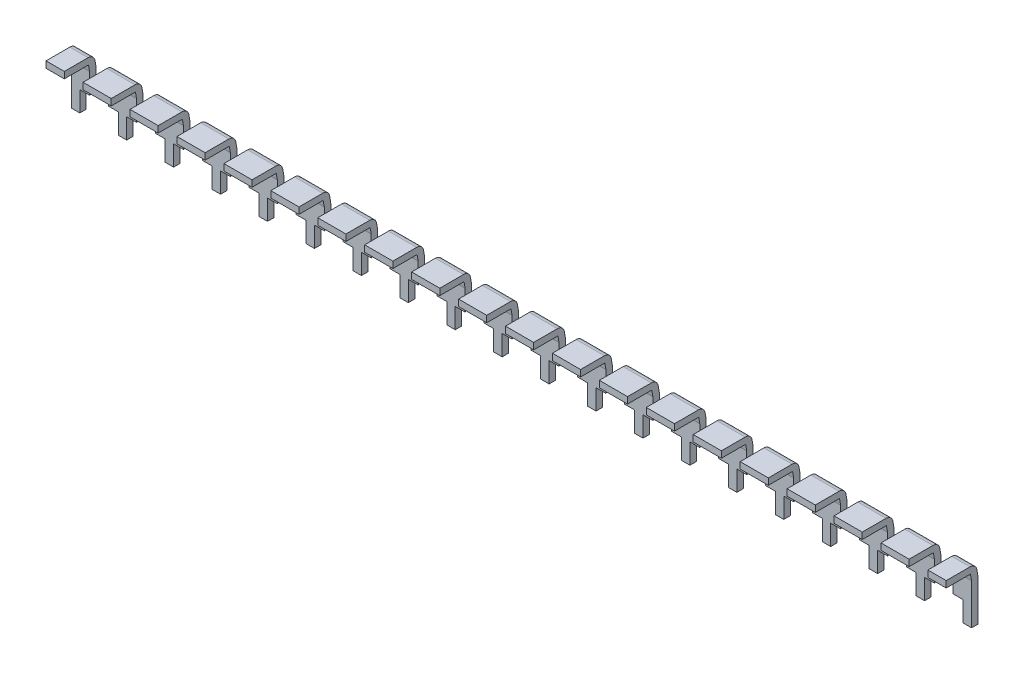
from build123d import *

# Parameters (mm, degrees)
SKETCH1_W      = 1.524
SKETCH1_H      = 0.35
SKETCH1_W_2    = 0.9906
SKETCH10_W     = 0.5334
SKETCH10_H     = 1.139083415
EXTRUDE1_DEPTH = 3.082895174


with BuildPart() as part:
    # Sweep11: sweep along a path in Sketch2
    with BuildLine(Plane(origin=(0, 0, 0), x_dir=(0, 0, -1), z_dir=(1, 0, 0))) as sweep11_path:
        Line((0, 0), (1.289016583, 0))
        ThreePointArc((1.289016583, 0), (1.417574105, -0.046791111), (1.485978134, -0.165270364))
        Line((1.485978134, -0.165270364), (1.541961551, -0.482768097))
        ThreePointArc((1.541961551, -0.482768097), (1.54423894, -0.500066584), (1.545, -0.517497733))
        Line((1.545, -0.517497733), (1.545, -2.725))
    # Sketch1 → Sweep11 (sweep)
    with BuildSketch(Plane.XY):
        with Locations((-1.27, 0)):
            Rectangle(SKETCH1_W, SKETCH1_H)
        with Locations((21.59, 0)):
            Rectangle(SKETCH1_W, SKETCH1_H)
        with Locations((23.8633, 0)):
            Rectangle(SKETCH1_W_2, SKETCH1_H)
        with Locations((-23.8633, 0)):
            Rectangle(SKETCH1_W_2, SKETCH1_H)
        with Locations((1.27, 0)):
            Rectangle(SKETCH1_W, SKETCH1_H)
        with Locations((3.81, 0)):
            Rectangle(SKETCH1_W, SKETCH1_H)
        with Locations((6.35, 0)):
            Rectangle(SKETCH1_W, SKETCH1_H)
        with Locations((8.89, 0)):
            Rectangle(SKETCH1_W, SKETCH1_H)
        with Locations((11.43, 0)):
            Rectangle(SKETCH1_W, SKETCH1_H)
        with Locations((13.97, 0)):
            Rectangle(SKETCH1_W, SKETCH1_H)
        with Locations((16.51, 0)):
            Rectangle(SKETCH1_W, SKETCH1_H)
        with Locations((19.05, 0)):
            Rectangle(SKETCH1_W, SKETCH1_H)
        with Locations((-3.81, 0)):
            Rectangle(SKETCH1_W, SKETCH1_H)
        with Locations((-6.35, 0)):
            Rectangle(SKETCH1_W, SKETCH1_H)
        with Locations((-8.89, 0)):
            Rectangle(SKETCH1_W, SKETCH1_H)
        with Locations((-11.43, 0)):
            Rectangle(SKETCH1_W, SKETCH1_H)
        with Locations((-13.97, 0)):
            Rectangle(SKETCH1_W, SKETCH1_H)
        with Locations((-16.51, 0)):
            Rectangle(SKETCH1_W, SKETCH1_H)
        with Locations((-19.05, 0)):
            Rectangle(SKETCH1_W, SKETCH1_H)
        with Locations((-21.59, 0)):
            Rectangle(SKETCH1_W, SKETCH1_H)
    sweep(path=sweep11_path.line)

    # Sketch10 → Extrude1 (cut, through all)
    with BuildSketch(Plane(origin=(0, 0.279522147, -1.585248871), x_dir=(-1, 0, 0), z_dir=(0, 0.173648178, -0.984807753))):
        with Locations((-23.6347, -2.412734286)):
            Rectangle(SKETCH10_W, SKETCH10_H)
        with Locations((-22.0853, -2.412734286)):
            Rectangle(SKETCH10_W, SKETCH10_H)
        with Locations((-21.0947, -2.412734286)):
            Rectangle(SKETCH10_W, SKETCH10_H)
        with Locations((-19.5453, -2.412734286)):
            Rectangle(SKETCH10_W, SKETCH10_H)
        with Locations((-18.5547, -2.412734286)):
            Rectangle(SKETCH10_W, SKETCH10_H)
        with Locations((23.6347, -2.412734286)):
            Rectangle(SKETCH10_W, SKETCH10_H)
        with Locations((-17.0053, -2.412734286)):
            Rectangle(SKETCH10_W, SKETCH10_H)
        with Locations((-16.0147, -2.412734286)):
            Rectangle(SKETCH10_W, SKETCH10_H)
        with Locations((-14.4653, -2.412734286)):
            Rectangle(SKETCH10_W, SKETCH10_H)
        with Locations((-13.4747, -2.412734286)):
            Rectangle(SKETCH10_W, SKETCH10_H)
        with Locations((-11.9253, -2.412734286)):
            Rectangle(SKETCH10_W, SKETCH10_H)
        with Locations((-10.9347, -2.412734286)):
            Rectangle(SKETCH10_W, SKETCH10_H)
        with Locations((-9.3853, -2.412734286)):
            Rectangle(SKETCH10_W, SKETCH10_H)
        with Locations((-8.3947, -2.412734286)):
            Rectangle(SKETCH10_W, SKETCH10_H)
        with Locations((-6.8453, -2.412734286)):
            Rectangle(SKETCH10_W, SKETCH10_H)
        with Locations((-5.8547, -2.412734286)):
            Rectangle(SKETCH10_W, SKETCH10_H)
        with Locations((-4.3053, -2.412734286)):
            Rectangle(SKETCH10_W, SKETCH10_H)
        with Locations((-3.3147, -2.412734286)):
            Rectangle(SKETCH10_W, SKETCH10_H)
        with Locations((-1.7653, -2.412734286)):
            Rectangle(SKETCH10_W, SKETCH10_H)
        with Locations((-0.7747, -2.412734286)):
            Rectangle(SKETCH10_W, SKETCH10_H)
        with Locations((0.7747, -2.412734286)):
            Rectangle(SKETCH10_W, SKETCH10_H)
        with Locations((1.7653, -2.412734286)):
            Rectangle(SKETCH10_W, SKETCH10_H)
        with Locations((3.3147, -2.412734286)):
            Rectangle(SKETCH10_W, SKETCH10_H)
        with Locations((4.3053, -2.412734286)):
            Rectangle(SKETCH10_W, SKETCH10_H)
        with Locations((5.8547, -2.412734286)):
            Rectangle(SKETCH10_W, SKETCH10_H)
        with Locations((6.8453, -2.412734286)):
            Rectangle(SKETCH10_W, SKETCH10_H)
        with Locations((8.3947, -2.412734286)):
            Rectangle(SKETCH10_W, SKETCH10_H)
        with Locations((9.3853, -2.412734286)):
            Rectangle(SKETCH10_W, SKETCH10_H)
        with Locations((10.9347, -2.412734286)):
            Rectangle(SKETCH10_W, SKETCH10_H)
        with Locations((11.9253, -2.412734286)):
            Rectangle(SKETCH10_W, SKETCH10_H)
        with Locations((13.4747, -2.412734286)):
            Rectangle(SKETCH10_W, SKETCH10_H)
        with Locations((14.4653, -2.412734286)):
            Rectangle(SKETCH10_W, SKETCH10_H)
        with Locations((16.0147, -2.412734286)):
            Rectangle(SKETCH10_W, SKETCH10_H)
        with Locations((17.0053, -2.412734286)):
            Rectangle(SKETCH10_W, SKETCH10_H)
        with Locations((18.5547, -2.412734286)):
            Rectangle(SKETCH10_W, SKETCH10_H)
        with Locations((19.5453, -2.412734286)):
            Rectangle(SKETCH10_W, SKETCH10_H)
        with Locations((21.0947, -2.412734286)):
            Rectangle(SKETCH10_W, SKETCH10_H)
        with Locations((22.0853, -2.412734286)):
            Rectangle(SKETCH10_W, SKETCH10_H)
    extrude(amount=-EXTRUDE1_DEPTH, mode=Mode.SUBTRACT)


solid = part.part
